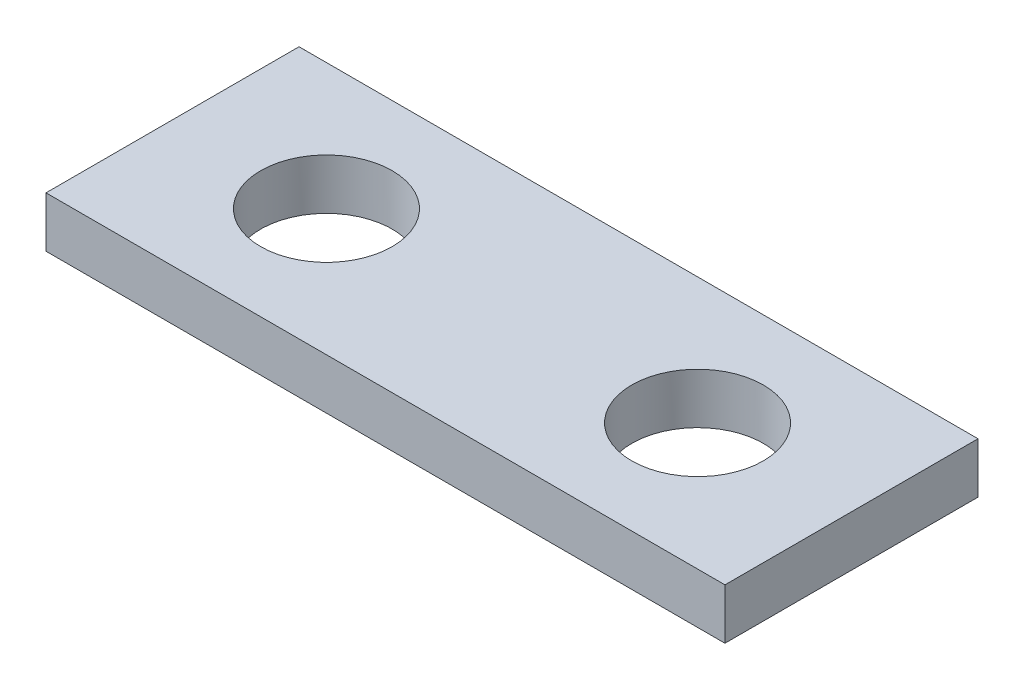
from build123d import *

# Parameters (mm, degrees)
SKETCH1_W           = 40.25
SKETCH1_H           = 15
BOSS_EXTRUDE1_DEPTH = 3
CUT_EXTRUDE1_START  = -4
SKETCH2_R           = 3.9
CUT_EXTRUDE1_DEPTH  = 5


with BuildPart() as part:
    # Sketch1 → Boss-Extrude1 (new body)
    with BuildSketch(Plane(origin=(0, 0, 0), x_dir=(1, 0, 0), z_dir=(0, 1, 0))):
        Rectangle(SKETCH1_W, SKETCH1_H)
    extrude(amount=BOSS_EXTRUDE1_DEPTH)

    # Sketch2 → Cut-Extrude1 (cut)
    with BuildSketch(Plane(origin=(0, 3, 0), x_dir=(1, 0, 0), z_dir=(0, 1, 0)).offset(CUT_EXTRUDE1_START)):
        with Locations((-11, 0)):
            Circle(SKETCH2_R)
    cut_extrude1 = extrude(amount=CUT_EXTRUDE1_DEPTH, mode=Mode.SUBTRACT)

    # Mirror1: Cut-Extrude1 across plane
    add(cut_extrude1.mirror(Plane(origin=(0, 0, 0), x_dir=(0, 0, 1), z_dir=(1, 0, 0))), mode=Mode.SUBTRACT)


solid = part.part
